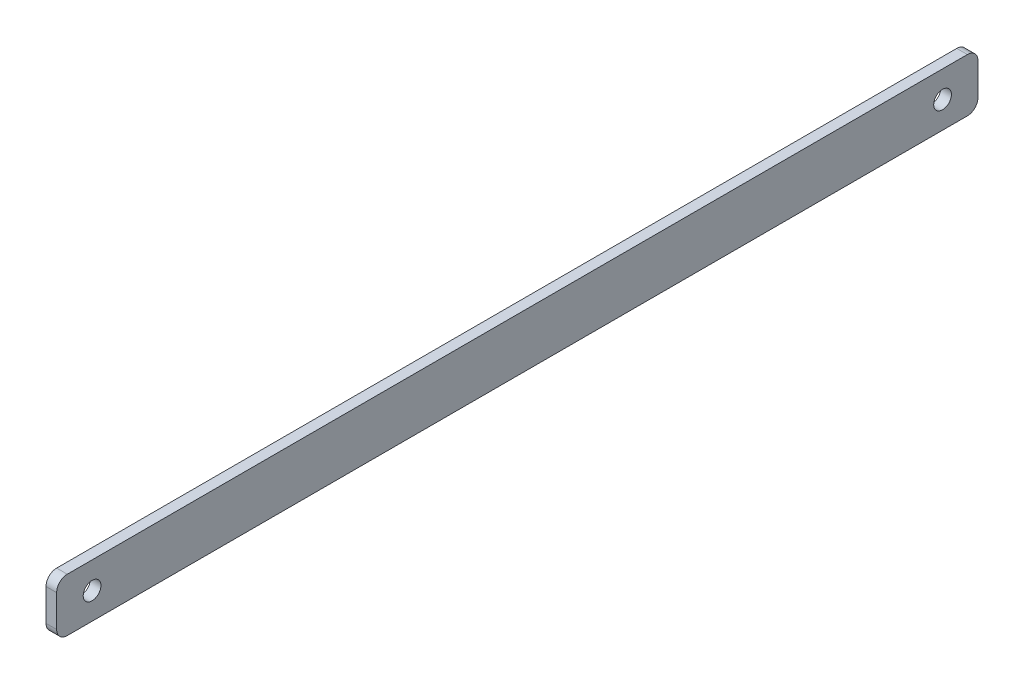
from build123d import *

# Parameters (mm, degrees)
SKETCH_1_R      = 2.5
EXTRUDE_1_DEPTH = 3


with BuildPart() as part:
    # Эскиз1 → Бобышка-Вытянуть1 (new body)
    with BuildSketch(Plane(origin=(0, 0, 0), x_dir=(0, 0, -1), z_dir=(1, 0, 0))):
        with BuildLine():
            Line((-127, 7.5), (127, 7.5))
            ThreePointArc((127, 7.5), (129.121320344, 6.621320344), (130, 4.5))
            Line((130, 4.5), (130, -4.5))
            ThreePointArc((130, -4.5), (129.121320344, -6.621320344), (127, -7.5))
            Line((127, -7.5), (-127, -7.5))
            ThreePointArc((-127, -7.5), (-129.121320344, -6.621320344), (-130, -4.5))
            Line((-130, -4.5), (-130, 4.5))
            ThreePointArc((-130, 4.5), (-129.121320344, 6.621320344), (-127, 7.5))
        make_face()
        with Locations((-120, 0)):
            Circle(SKETCH_1_R, mode=Mode.SUBTRACT)
        with Locations((120, 0)):
            Circle(SKETCH_1_R, mode=Mode.SUBTRACT)
    extrude(amount=EXTRUDE_1_DEPTH)


solid = part.part
